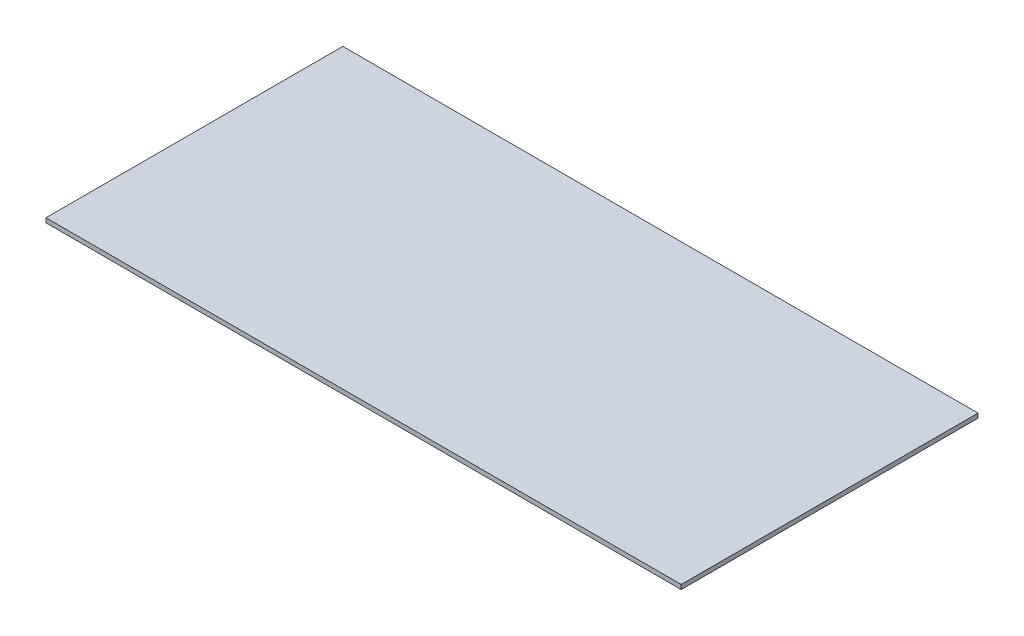
from build123d import *

# Parameters (mm, degrees)
ESQUISSE1_W        = 428
ESQUISSE1_H        = 200
BOSS_EXTRU_1_DEPTH = 3


with BuildPart() as part:
    # Esquisse1 → Boss.-Extru.1 (new body)
    with BuildSketch(Plane(origin=(0, 0, 0), x_dir=(1, 0, 0), z_dir=(0, 1, 0))):
        with Locations((0, 5)):
            Rectangle(ESQUISSE1_W, ESQUISSE1_H)
    extrude(amount=BOSS_EXTRU_1_DEPTH)


solid = part.part
